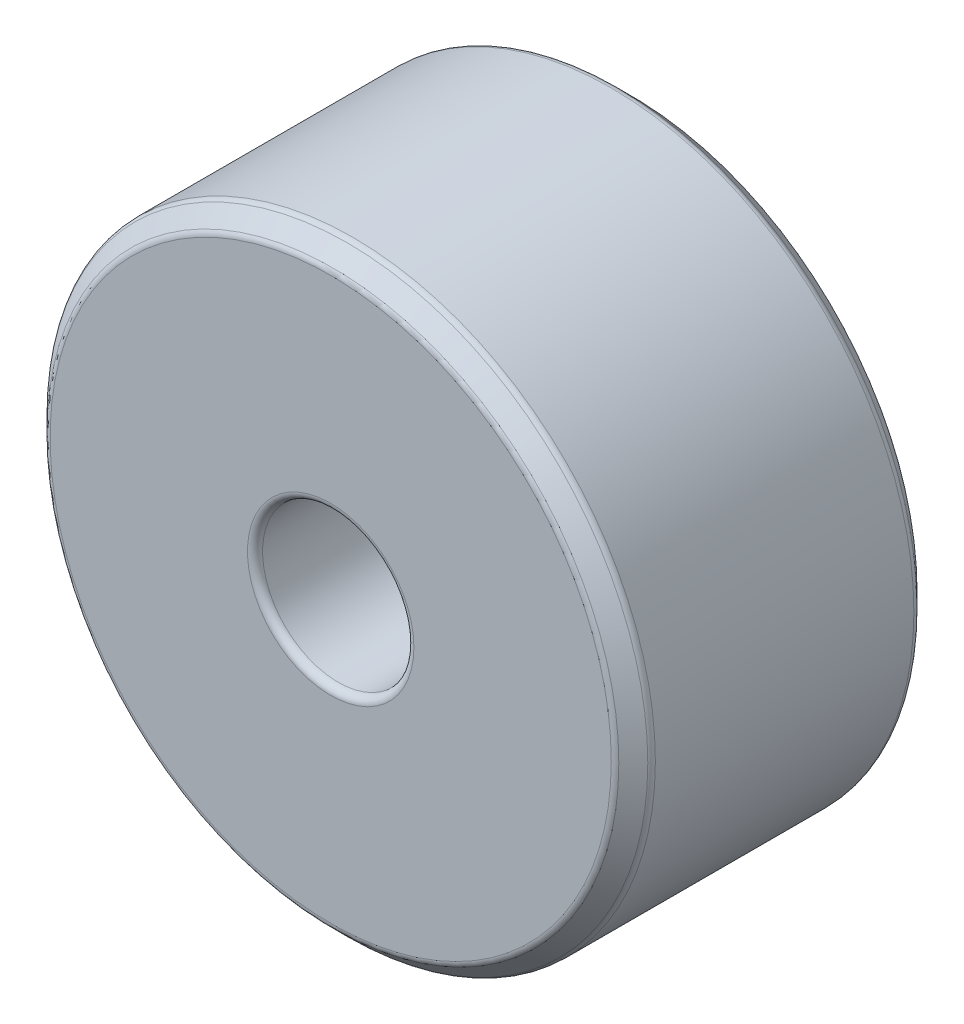
from build123d import *

# Parameters (mm, degrees)
SKETCH2_R           = 4
SKETCH2_R_2         = 1
BOSS_EXTRUDE1_DEPTH = 4
CHAMFER1_SIZE       = 0.25
FILLET1_R           = 0.1


with BuildPart() as part:
    # Sketch2 → Boss-Extrude1 (new body)
    with BuildSketch(Plane.XY):
        Circle(SKETCH2_R)
        Circle(SKETCH2_R_2, mode=Mode.SUBTRACT)
    extrude(amount=BOSS_EXTRUDE1_DEPTH)

    # Chamfer1
    chamfer1_edges = [part.edges().sort_by_distance(p)[0] for p in [
        (-4, 0, 0),
        (-4, 0, 4),
    ]]
    chamfer(chamfer1_edges, length=CHAMFER1_SIZE)

    # Fillet1
    fillet1_edges = [part.edges().sort_by_distance(p)[0] for p in [
        (-4, 0, 0.25),
        (-3.75, 0, 0),
        (-3.75, 0, 4),
        (-1, 0, 0),
        (-1, 0, 4),
        (-4, 0, 3.75),
    ]]
    fillet(fillet1_edges, radius=FILLET1_R)


solid = part.part
